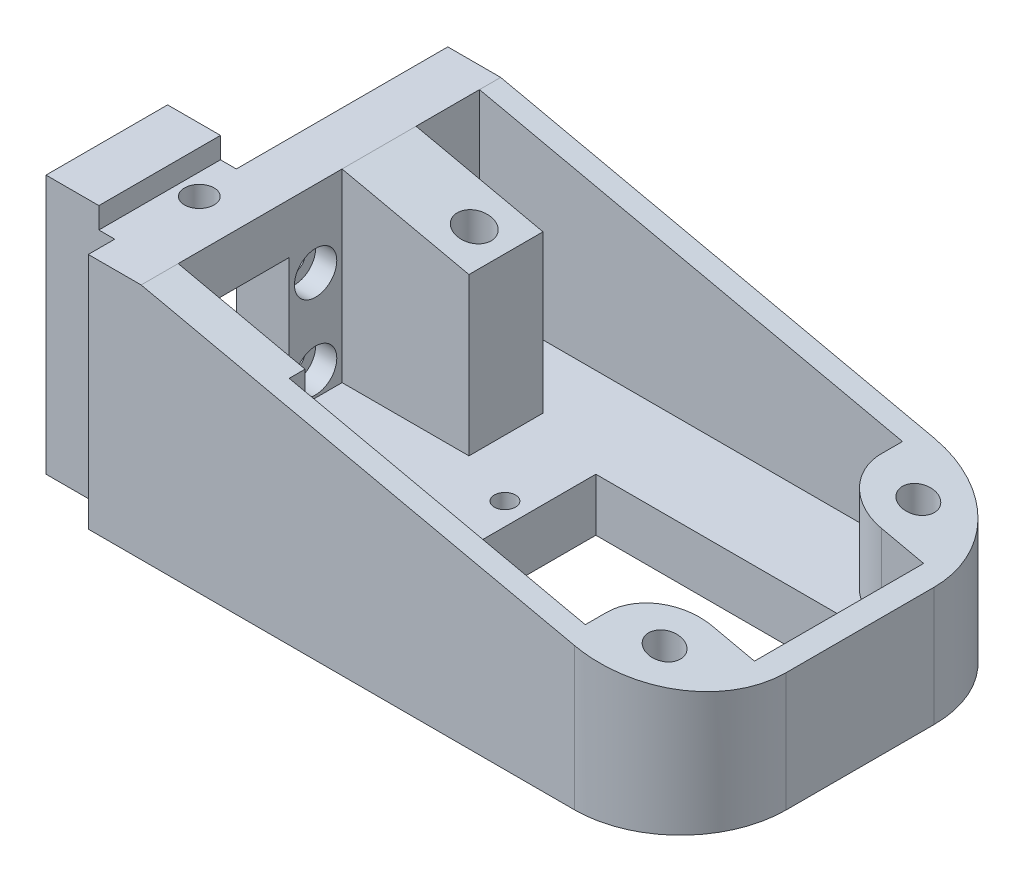
from build123d import *

# Parameters (mm, degrees)
BOSS_EXTRUDE1_DEPTH     = 22.5
CUT_EXTRUDE1_DEPTH      = 17.5
SKETCH4_R               = 1
CUT_EXTRUDE2_DEPTH      = 15
CUT_EXTRUDE2_DEPTH_BACK = 12.5
SKETCH5_W               = 10.5
SKETCH5_H               = 12.5
CUT_EXTRUDE3_DEPTH      = 20
SKETCH6_R               = 1.4
CUT_EXTRUDE4_DEPTH      = 10
SKETCH8_R               = 1
SKETCH8_W               = 24
SKETCH8_H               = 13
CUT_EXTRUDE6_DEPTH      = 6
SKETCH9_R               = 1.5
CUT_EXTRUDE7_DEPTH      = 23.5
SKETCH10_R              = 3
CUT_EXTRUDE8_DEPTH      = 5
SKETCH14_W              = 12
SKETCH14_H              = 17.5
BOSS_EXTRUDE3_DEPTH     = 3.5
SKETCH11_R              = 1.5
CUT_EXTRUDE9_DEPTH      = 10
SKETCH16_R              = 2
CUT_EXTRUDE11_DEPTH     = 2
SKETCH18_W              = 6.5
SKETCH18_H              = 2.5
CUT_EXTRUDE12_DEPTH     = 23.5
CUT_EXTRUDE14_DEPTH     = 35
SKETCH22_R              = 1.6
CUT_EXTRUDE15_DEPTH     = 23.5
SKETCH23_R              = 3
CUT_EXTRUDE18_DEPTH     = 3
SKETCH25_W              = 5
SKETCH25_H              = 11.5
BOSS_EXTRUDE4_DEPTH     = 2


with BuildPart() as part:
    # Sketch2 → Boss-Extrude1 (new body)
    with BuildSketch(Plane(origin=(0, 0, 0), x_dir=(1, 0, 0), z_dir=(0, 1, 0))):
        with BuildLine():
            Line((0, 0), (46, 0))
            ThreePointArc((46, 0), (53.071067812, 2.928932188), (56, 10))
            Line((56, 10), (56, 24))
            ThreePointArc((56, 24), (53.071067812, 31.071067812), (46, 34))
            Line((46, 34), (0, 34))
            Line((0, 34), (0, 14))
            Line((0, 14), (-6.5, 14))
            Line((-6.5, 14), (-6.5, 0))
            Line((-6.5, 0), (0, 0))
        make_face()
    extrude(amount=BOSS_EXTRUDE1_DEPTH)

    # Sketch3 → Cut-Extrude1 (cut)
    with BuildSketch(Plane(origin=(0, 22.5, 0), x_dir=(1, 0, 0), z_dir=(0, 1, 0))):
        with BuildLine():
            Line((45, 32), (5, 32))
            Line((5, 32), (5, 3.5))
            Line((5, 3.5), (17, 3.5))
            Line((17, 3.5), (17, 2))
            Line((17, 2), (45, 2))
            Line((45, 2), (45, 4))
            ThreePointArc((45, 4), (46.464466094, 7.535533906), (50, 9))
            Line((50, 9), (54, 9))
            Line((54, 9), (54, 25))
            Line((54, 25), (50, 25))
            ThreePointArc((50, 25), (46.464466094, 26.464466094), (45, 30))
            Line((45, 30), (45, 32))
        make_face()
    extrude(amount=-CUT_EXTRUDE1_DEPTH, mode=Mode.SUBTRACT)

    # Sketch4 → Cut-Extrude2 (cut, two sides)
    with BuildSketch(Plane(origin=(5, 0, 0), x_dir=(0, 0, -1), z_dir=(1, 0, 0))) as cut_extrude2_sk:
        with Locations((28.5, 15.25)):
            Circle(SKETCH4_R)
        with Locations((28.5, 7.25)):
            Circle(SKETCH4_R)
        with Locations((16.5, 7.25)):
            Circle(SKETCH4_R)
        with Locations((16.5, 15.25)):
            Circle(SKETCH4_R)
    extrude(amount=CUT_EXTRUDE2_DEPTH, mode=Mode.SUBTRACT)
    extrude(cut_extrude2_sk.sketch, amount=-CUT_EXTRUDE2_DEPTH_BACK, mode=Mode.SUBTRACT)

    # Sketch5 → Cut-Extrude3 (cut)
    with BuildSketch(Plane.ZY.offset(6.5)):
        with Locations((-8.75, 11.5)):
            Rectangle(SKETCH5_W, SKETCH5_H)
    extrude(amount=-CUT_EXTRUDE3_DEPTH, mode=Mode.SUBTRACT)

    # Sketch6 → Cut-Extrude4 (cut)
    with BuildSketch(Plane(origin=(0, 22.5, 0), x_dir=(1, 0, 0), z_dir=(0, 1, 0))):
        with Locations((0.5, 10)):
            Circle(SKETCH6_R)
    extrude(amount=-CUT_EXTRUDE4_DEPTH, mode=Mode.SUBTRACT)

    # Sketch8 → Cut-Extrude6 (cut, through all)
    with BuildSketch(Plane(origin=(0, 5, 0), x_dir=(1, 0, 0), z_dir=(0, 1, 0))):
        with Locations((50.6, 17)):
            Circle(SKETCH8_R)
        with Locations((22.4, 17)):
            Circle(SKETCH8_R)
        with Locations((36.5, 17)):
            Rectangle(SKETCH8_W, SKETCH8_H)
    extrude(amount=-CUT_EXTRUDE6_DEPTH, mode=Mode.SUBTRACT)

    # Sketch9 → Cut-Extrude7 (cut, through all)
    with BuildSketch(Plane(origin=(0, 22.5, 0), x_dir=(1, 0, 0), z_dir=(0, 1, 0))):
        with Locations((49.5, 29)):
            Circle(SKETCH9_R)
        with Locations((49.5, 5)):
            Circle(SKETCH9_R)
    extrude(amount=-CUT_EXTRUDE7_DEPTH, mode=Mode.SUBTRACT)

    # Sketch10 → Cut-Extrude8 (cut)
    with BuildSketch(Plane.XZ):
        with Locations((49.5, -5)):
            Circle(SKETCH10_R)
        with Locations((49.5, -29)):
            Circle(SKETCH10_R)
    extrude(amount=-CUT_EXTRUDE8_DEPTH, mode=Mode.SUBTRACT)

    # Sketch14 → Boss-Extrude3 (add, symmetric)
    with BuildSketch(Plane.XY.offset(-22.5)):
        with Locations((11, 13.75)):
            Rectangle(SKETCH14_W, SKETCH14_H)
    extrude(amount=BOSS_EXTRUDE3_DEPTH, both=True)

    # Sketch11 → Cut-Extrude9 (cut)
    with BuildSketch(Plane.XZ):
        with Locations((8, -8)):
            Circle(SKETCH11_R)
        with Locations((8, -26)):
            Circle(SKETCH11_R)
    extrude(amount=-CUT_EXTRUDE9_DEPTH, mode=Mode.SUBTRACT)

    # Sketch16 → Cut-Extrude11 (cut)
    with BuildSketch(Plane(origin=(5, 0, 0), x_dir=(0, 0, -1), z_dir=(1, 0, 0))):
        with Locations((28.5, 15.25)):
            Circle(SKETCH16_R)
        with Locations((28.5, 7.25)):
            Circle(SKETCH16_R)
        with Locations((16.5, 7.25)):
            Circle(SKETCH16_R)
        with Locations((16.5, 15.25)):
            Circle(SKETCH16_R)
    extrude(amount=-CUT_EXTRUDE11_DEPTH, mode=Mode.SUBTRACT)

    # Sketch18 → Cut-Extrude12 (cut, through all)
    with BuildSketch(Plane(origin=(0, 22.5, 0), x_dir=(1, 0, 0), z_dir=(0, 1, 0))):
        with Locations((-3.25, 1.25)):
            Rectangle(SKETCH18_W, SKETCH18_H)
    extrude(amount=-CUT_EXTRUDE12_DEPTH, mode=Mode.SUBTRACT)

    # Sketch21 → Cut-Extrude14 (cut, through all)
    with BuildSketch(Plane.XY):
        Polygon((5, 22.5), (56, 11.25), (56, 22.5), align=None)
    extrude(amount=-CUT_EXTRUDE14_DEPTH, mode=Mode.SUBTRACT)

    # Sketch22 → Cut-Extrude15 (cut, through all)
    with BuildSketch(Plane.XZ):
        with Locations((14, -22.5)):
            Circle(SKETCH22_R)
    extrude(amount=-CUT_EXTRUDE15_DEPTH, mode=Mode.SUBTRACT)

    # Sketch23 → Cut-Extrude18 (cut)
    with BuildSketch(Plane.XZ):
        with Locations((14, -22.5)):
            Circle(SKETCH23_R)
    extrude(amount=-CUT_EXTRUDE18_DEPTH, mode=Mode.SUBTRACT)

    # Sketch25 → Boss-Extrude4 (add)
    with BuildSketch(Plane(origin=(0, 22.5, 0), x_dir=(1, 0, 0), z_dir=(0, 1, 0))):
        with Locations((-4, 8.25)):
            Rectangle(SKETCH25_W, SKETCH25_H)
    extrude(amount=BOSS_EXTRUDE4_DEPTH)


solid = part.part
